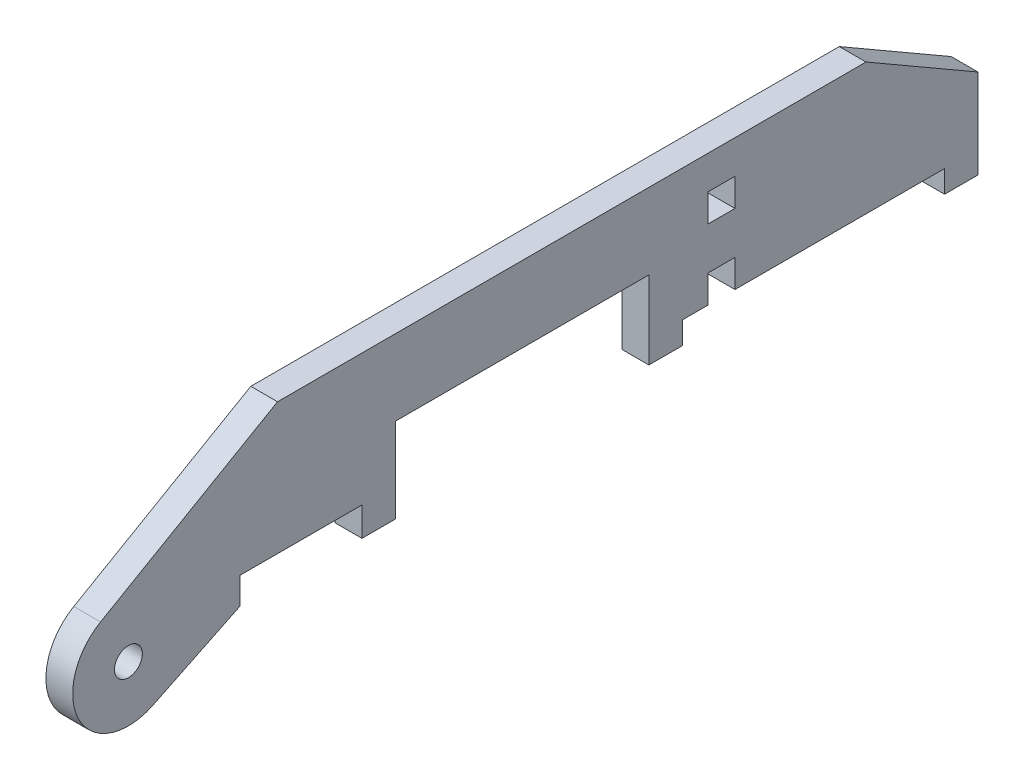
from build123d import *

# Parameters (mm, degrees)
SKETCH1_R           = 3.175
SKETCH1_W           = 6.096
SKETCH1_H           = 6.35
BOSS_EXTRUDE1_DEPTH = 3.048


with BuildPart() as part:
    # Sketch1 → Boss-Extrude1 (new, symmetric)
    with BuildSketch(Plane(origin=(0, 0, 0), x_dir=(0, 0, -1), z_dir=(1, 0, 0))):
        with BuildLine():
            Line((-94.642365809, 55.626), (-122.457292876, 55.626))
            Line((-122.457292876, 55.626), (-122.457292876, 49.53))
            Line((-122.457292876, 49.53), (-142.309833129, 39.889958968))
            ThreePointArc((-142.309833129, 39.889958968), (-159.075906045, 45.361766519), (-154.207292876, 62.312827982))
            Line((-154.207292876, 62.312827982), (-113.876191878, 85.598))
            Line((-113.876191878, 85.598), (20.203427503, 85.598))
            Line((20.203427503, 85.598), (45.72, 70.866))
            Line((45.72, 70.866), (45.72, 50.546))
            Line((45.72, 50.546), (38.1, 50.546))
            Line((38.1, 50.546), (38.1, 55.626))
            Line((38.1, 55.626), (-9.652, 55.626))
            Line((-9.652, 55.626), (-9.652, 61.976))
            Line((-9.652, 61.976), (-15.748, 61.976))
            Line((-15.748, 61.976), (-15.748, 55.626))
            Line((-15.748, 55.626), (-21.651856626, 55.626))
            Line((-21.651856626, 55.626), (-21.651856626, 50.546))
            Line((-21.651856626, 50.546), (-29.271856626, 50.546))
            Line((-29.271856626, 50.546), (-29.271856626, 68.326))
            Line((-29.271856626, 68.326), (-87.022365809, 68.326))
            Line((-87.022365809, 68.326), (-87.022365809, 49.022))
            Line((-87.022365809, 49.022), (-94.642365809, 49.022))
            Line((-94.642365809, 49.022), (-94.642365809, 55.626))
        make_face()
        with Locations((-147.857292876, 51.314305354)):
            Circle(SKETCH1_R, mode=Mode.SUBTRACT)
        with Locations((-12.7, 74.803)):
            Rectangle(SKETCH1_W, SKETCH1_H, mode=Mode.SUBTRACT)
    extrude(amount=BOSS_EXTRUDE1_DEPTH, both=True)


solid = part.part
